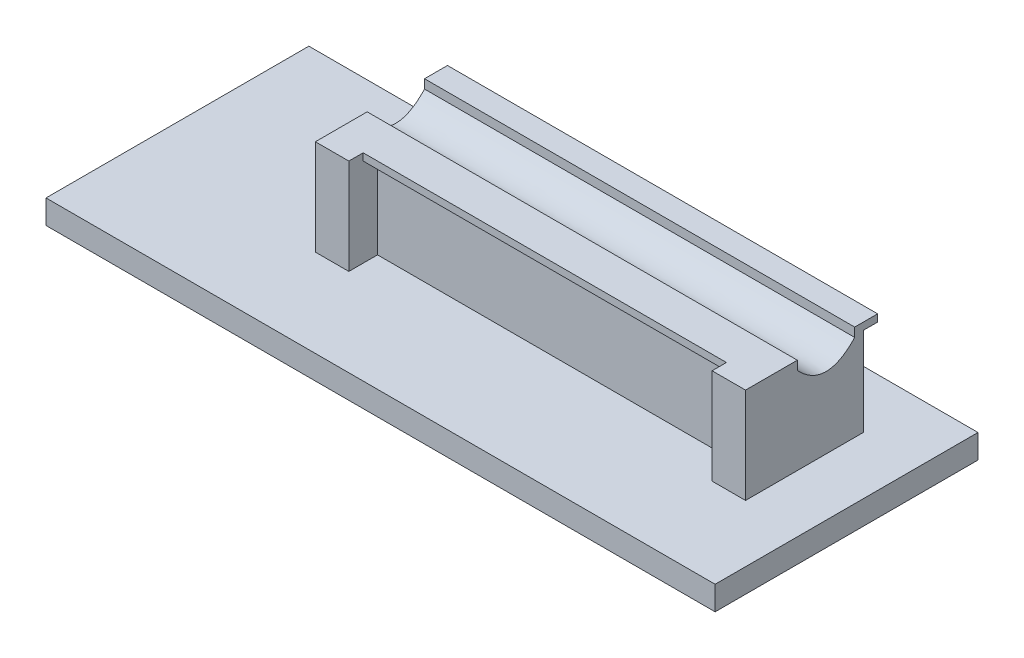
from build123d import *

# Parameters (mm, degrees)
SKETCH2_W           = 186.37
SKETCH2_H           = 200
BOSS_EXTRUDE2_DEPTH = 900
SKETCH3_W           = 70
SKETCH3_H           = 200
BOSS_EXTRUDE3_DEPTH = 60
SKETCH4_W           = 1400
SKETCH4_H           = 550
BOSS_EXTRUDE4_DEPTH = 50
CUT_EXTRUDE1_DEPTH  = 900
SKETCH7_W           = 900
SKETCH7_H           = 15
BOSS_EXTRUDE5_DEPTH = 30
SKETCH8_W           = 760
SKETCH8_H           = 15
BOSS_EXTRUDE6_DEPTH = 30


with BuildPart() as part:
    # Sketch2 → Boss-Extrude2 (new body)
    with BuildSketch(Plane(origin=(0, 0, 0), x_dir=(0, 0, -1), z_dir=(1, 0, 0))):
        Rectangle(SKETCH2_W, SKETCH2_H)
    extrude(amount=-BOSS_EXTRUDE2_DEPTH)

    # Sketch3 → Boss-Extrude3 (add)
    with BuildSketch(Plane.XY.offset(93.185)):
        with Locations((-35, 0)):
            Rectangle(SKETCH3_W, SKETCH3_H)
        with Locations((-865, 0)):
            Rectangle(SKETCH3_W, SKETCH3_H)
    extrude(amount=BOSS_EXTRUDE3_DEPTH)

    # Sketch4 → Boss-Extrude4 (add)
    with BuildSketch(Plane.XZ.offset(100)):
        with Locations((-580, 61.815)):
            Rectangle(SKETCH4_W, SKETCH4_H)
    extrude(amount=BOSS_EXTRUDE4_DEPTH)

    # Sketch6 → Cut-Extrude1 (cut)
    with BuildSketch(Plane(origin=(0, 0, 0), x_dir=(0, 0, -1), z_dir=(1, 0, 0))):
        with BuildLine():
            Line((-44.815, 100), (-44.815, 81.242091756))
            add(Edge.make_bspline(
                [(-44.815, 81.242091756), (15.185, 17.399871026), (75.185, 81.242091756)],
                knots=[0, 0, 0, 1, 1, 1], degree=2))
            Line((75.185, 81.242091756), (75.185, 100))
            Line((75.185, 100), (-44.815, 100))
        make_face()
    extrude(amount=-CUT_EXTRUDE1_DEPTH, mode=Mode.SUBTRACT)

    # Sketch7 → Boss-Extrude5 (add)
    with BuildSketch(Plane(origin=(0, 0, -93.185), x_dir=(-1, 0, 0), z_dir=(0, 0, -1))):
        with Locations((450, 92.5)):
            Rectangle(SKETCH7_W, SKETCH7_H)
    extrude(amount=BOSS_EXTRUDE5_DEPTH)

    # Sketch8 → Boss-Extrude6 (add)
    with BuildSketch(Plane.XY.offset(93.185)):
        with Locations((-450, 92.5)):
            Rectangle(SKETCH8_W, SKETCH8_H)
    extrude(amount=BOSS_EXTRUDE6_DEPTH)


solid = part.part
